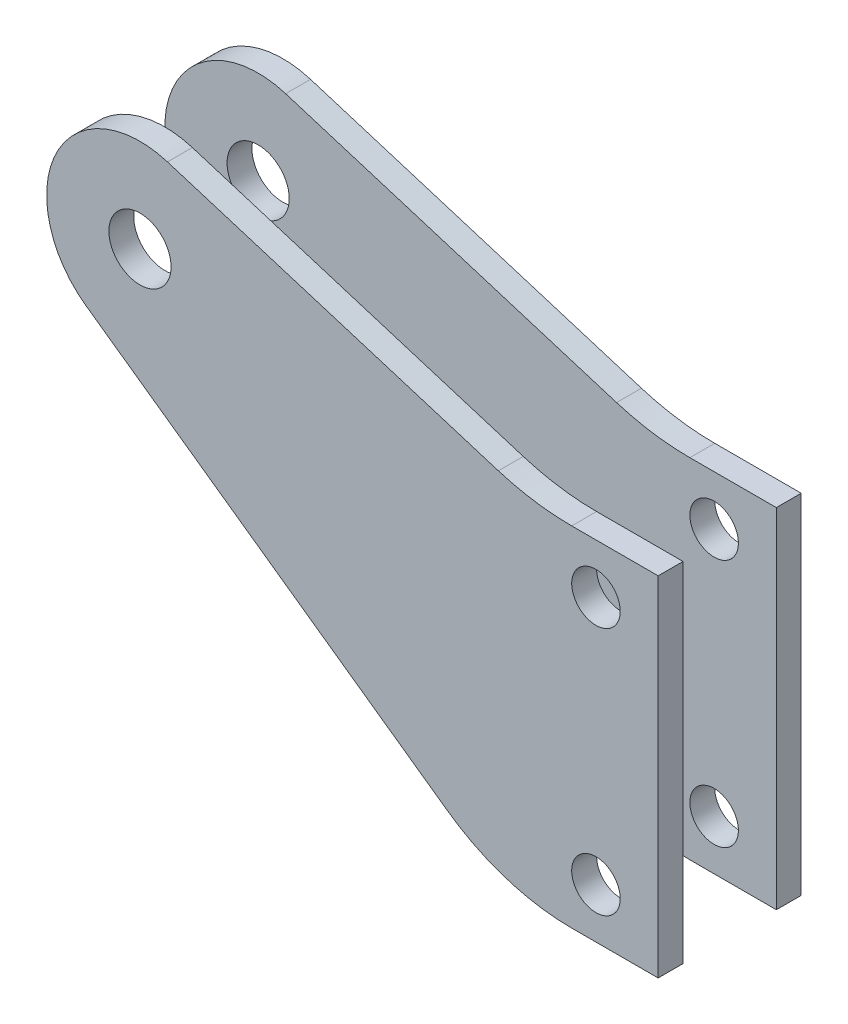
from build123d import *

# Parameters (mm, degrees)
STEERING_START     = 4.7625
SKETCH1_R          = 2.4765
SKETCH1_R_2        = 3.175
STEERING_ARM_DEPTH = 2.54


with BuildPart() as part:
    # Sketch1 → Steering Arm (new body)
    with BuildSketch(Plane.XY.offset(STEERING_START)):
        with BuildLine():
            Line((2.806864922, 9.102040118), (36.59240598, -1.316662595))
            ThreePointArc((36.59240598, -1.316662595), (40.292641158, -2.160999603), (44.077379106, -2.444555614))
            Line((44.077379106, -2.444555614), (52.903879106, -2.444555614))
            Line((52.903879106, -2.444555614), (52.903879106, -38.004555614))
            Line((52.903879106, -38.004555614), (44.077379106, -38.004555614))
            ThreePointArc((44.077379106, -38.004555614), (37.412396269, -36.967694276), (31.377379106, -33.955113074))
            Line((31.377379106, -33.955113074), (-5.513607921, -7.766965476))
            ThreePointArc((-5.513607921, -7.766965476), (-8.542391459, 4.213451454), (2.806864922, 9.102040118))
        make_face()
        with Locations((46.553879106, -7.524555614)):
            Circle(SKETCH1_R, mode=Mode.SUBTRACT)
        with Locations((46.553879106, -32.924555614)):
            Circle(SKETCH1_R, mode=Mode.SUBTRACT)
        Circle(SKETCH1_R_2, mode=Mode.SUBTRACT)
    extrude(amount=STEERING_ARM_DEPTH)


with BuildPart() as body_2:
    # Steering Arm Mirror: mirrored copy
    add(part.part.mirror(Plane.XY))


solid = Compound([part.part, body_2.part])
